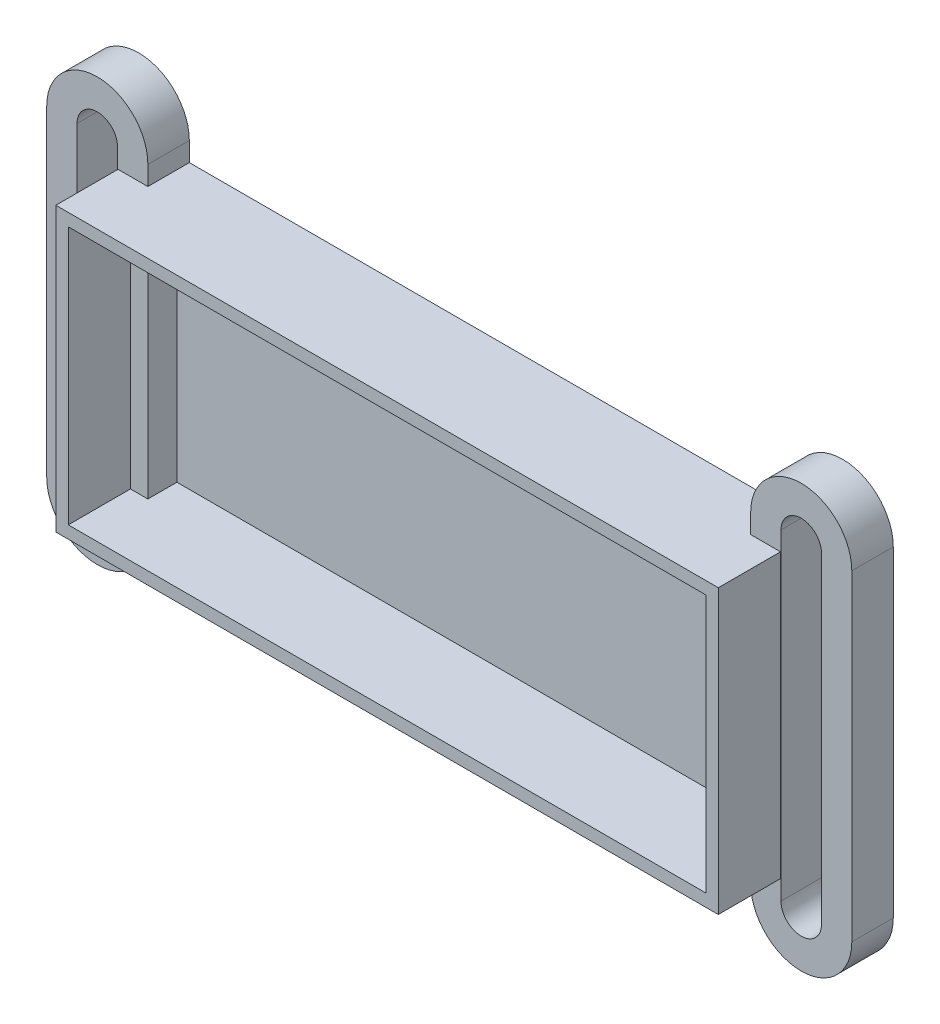
from build123d import *

# Parameters (mm, degrees)
BOSS_EXTRUDE1_DEPTH = 10
SKETCH2_W           = 63.9
SKETCH2_H           = 27.3
BOSS_EXTRUDE2_DEPTH = 1.2
BOSS_EXTRUDE3_DEPTH = 4


with BuildPart() as part:
    # 3DSketch1 → Boss-Extrude1 (new body)
    with BuildSketch(Plane(origin=(-40.430283892, 18.807335645, 0), x_dir=(0.9232075579857172, -0.3843017107404659, 0), z_dir=(0, 0, 1))):
        Polygon((-1.569011122, 0.646687017), (57.423951833, 25.203566333), (67.915388536, 0), (8.922425581, -24.556879316), align=None)
        Polygon((0, 0), (56.777264816, 23.634555211), (66.346377414, 0.646687017), (9.569112597, -22.987868194), align=None, mode=Mode.SUBTRACT)
    extrude(amount=BOSS_EXTRUDE1_DEPTH)

    # Sketch2 → Boss-Extrude2 (add)
    with BuildSketch(Plane(origin=(0, 0, 0), x_dir=(-1, 0, 0), z_dir=(0, 0, -1))):
        with Locations((9.680283892, 6.357335645)):
            Rectangle(SKETCH2_W, SKETCH2_H)
    extrude(amount=-BOSS_EXTRUDE2_DEPTH)

    # Sketch4 → Boss-Extrude3 (add)
    with BuildSketch(Plane(origin=(0, 0, 0), x_dir=(-1, 0, 0), z_dir=(0, 0, -1))):
        with BuildLine():
            Line((48.507458783, 21.857335645), (48.507458783, -9.142664355))
            ThreePointArc((48.507458783, -9.142664355), (43.630283892, -14.019839246), (38.753109001, -9.142664355))
            Line((38.753109001, -9.142664355), (38.753109001, 21.857335645))
            ThreePointArc((38.753109001, 21.857335645), (43.630283892, 26.734510536), (48.507458783, 21.857335645))
        make_face()
        with BuildLine():
            Line((45.58467524, 21.857335645), (45.58467524, -9.142664355))
            ThreePointArc((45.58467524, -9.142664355), (43.630283892, -11.097055703), (41.675892544, -9.142664355))
            Line((41.675892544, -9.142664355), (41.675892544, 21.857335645))
            ThreePointArc((41.675892544, 21.857335645), (43.630283892, 23.811726993), (45.58467524, 21.857335645))
        make_face(mode=Mode.SUBTRACT)
        with BuildLine():
            Line((-29.146890999, 21.857335645), (-29.146890999, -9.142664355))
            ThreePointArc((-29.146890999, -9.142664355), (-24.269716108, -14.019839246), (-19.392541217, -9.142664355))
            Line((-19.392541217, -9.142664355), (-19.392541217, 21.857335645))
            ThreePointArc((-19.392541217, 21.857335645), (-24.269716108, 26.734510536), (-29.146890999, 21.857335645))
        make_face()
        with BuildLine():
            Line((-26.224107456, 21.857335645), (-26.224107456, -9.142664355))
            ThreePointArc((-26.224107456, -9.142664355), (-24.269716108, -11.097055703), (-22.31532476, -9.142664355))
            Line((-22.31532476, -9.142664355), (-22.31532476, 21.857335645))
            ThreePointArc((-22.31532476, 21.857335645), (-24.269716108, 23.811726993), (-26.224107456, 21.857335645))
        make_face(mode=Mode.SUBTRACT)
    extrude(amount=-BOSS_EXTRUDE3_DEPTH)


solid = part.part
